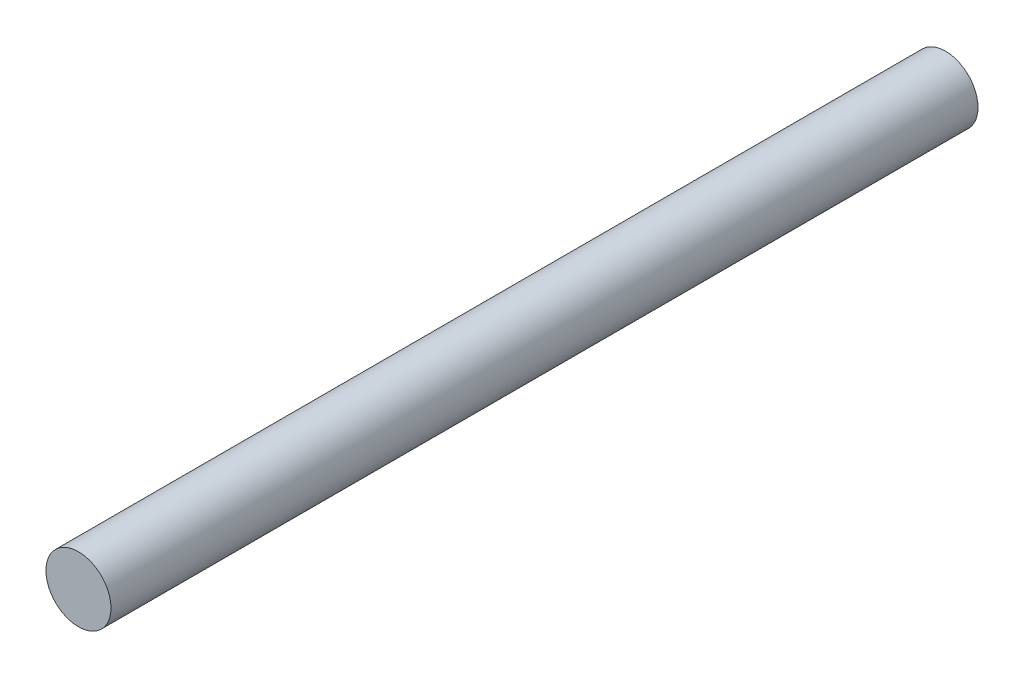
from build123d import *

# Parameters (mm, degrees)
SKETCH2_R           = 4.7625
BOSS_EXTRUDE1_DEPTH = 127


with BuildPart() as part:
    # Sketch2 → Boss-Extrude1 (new body)
    with BuildSketch(Plane.XY):
        Circle(SKETCH2_R)
    extrude(amount=BOSS_EXTRUDE1_DEPTH)


solid = part.part
